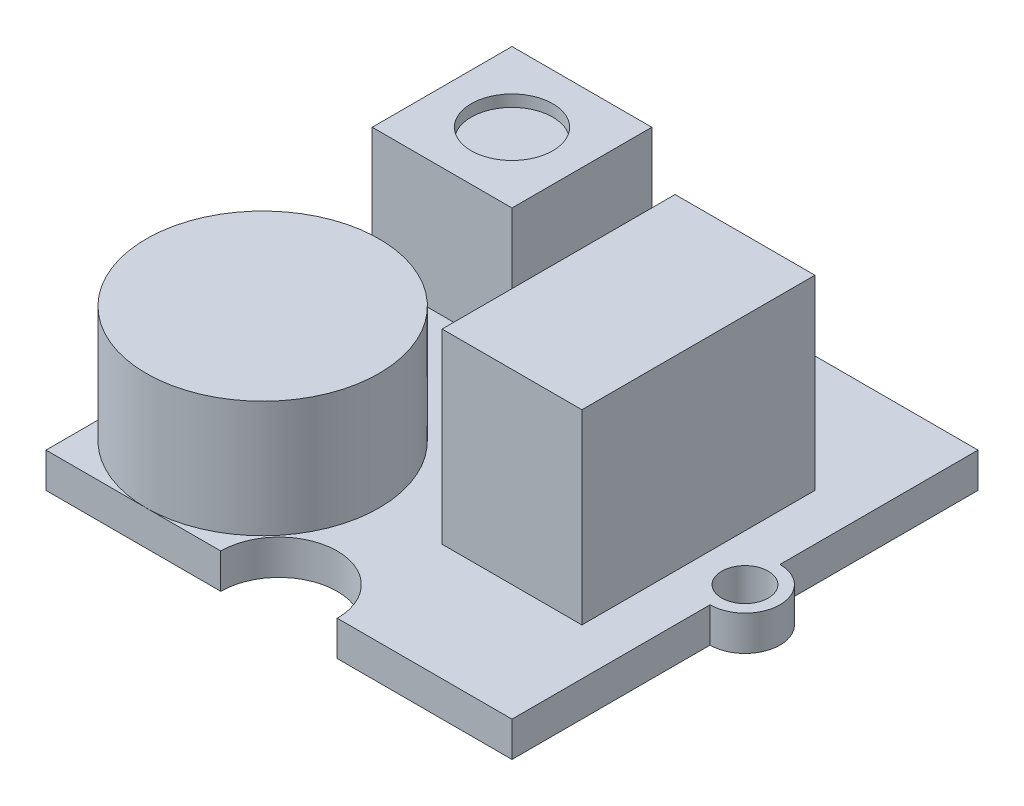
from build123d import *

# Parameters (mm, degrees)
SKETCH1_W           = 20
SKETCH1_H           = 20
BOSS_EXTRUDE1_DEPTH = 1.5
SKETCH2_R           = 1.5
BOSS_EXTRUDE2_DEPTH = 1.5
SKETCH3_R           = 1
SKETCH3_R_2         = 2.5
CUT_EXTRUDE1_DEPTH  = 1.5
SKETCH4_R           = 5
BOSS_EXTRUDE3_DEPTH = 5
SKETCH5_W           = 6
SKETCH5_H           = 6
BOSS_EXTRUDE4_DEPTH = 5.5
SKETCH6_W           = 6
SKETCH6_H           = 10
BOSS_EXTRUDE5_DEPTH = 8
SKETCH7_W           = 3
SKETCH7_H           = 1.820054299
BOSS_EXTRUDE6_DEPTH = 1
SKETCH8_R           = 1.75
CUT_EXTRUDE2_DEPTH  = 0.5


with BuildPart() as part:
    # Sketch1 → Boss-Extrude1 (new body)
    with BuildSketch(Plane(origin=(0, 0, 0), x_dir=(1, 0, 0), z_dir=(0, 1, 0))):
        Rectangle(SKETCH1_W, SKETCH1_H)
    extrude(amount=BOSS_EXTRUDE1_DEPTH)

    # Sketch2 → Boss-Extrude2 (add)
    with BuildSketch(Plane(origin=(0, 1.5, 0), x_dir=(1, 0, 0), z_dir=(0, 1, 0))):
        with Locations((-10, 0)):
            Circle(SKETCH2_R)
        with Locations((10, 0)):
            Circle(SKETCH2_R)
    extrude(amount=-BOSS_EXTRUDE2_DEPTH)

    # Sketch3 → Cut-Extrude1 (cut)
    with BuildSketch(Plane(origin=(0, 1.5, 0), x_dir=(1, 0, 0), z_dir=(0, 1, 0))):
        with Locations((-10, 0)):
            Circle(SKETCH3_R)
        with Locations((10, 0)):
            Circle(SKETCH3_R)
        with Locations((0, 10)):
            Circle(SKETCH3_R_2)
        with Locations((0, -10)):
            Circle(SKETCH3_R_2)
    extrude(amount=-CUT_EXTRUDE1_DEPTH, mode=Mode.SUBTRACT)

    # Sketch4 → Boss-Extrude3 (add)
    with BuildSketch(Plane(origin=(0, 1.5, 0), x_dir=(1, 0, 0), z_dir=(0, 1, 0))):
        with Locations((-5.7, -5)):
            Circle(SKETCH4_R)
    extrude(amount=BOSS_EXTRUDE3_DEPTH)

    # Sketch5 → Boss-Extrude4 (add)
    with BuildSketch(Plane(origin=(0, 1.5, 0), x_dir=(1, 0, 0), z_dir=(0, 1, 0))):
        with Locations((-6.5, 6.5)):
            Rectangle(SKETCH5_W, SKETCH5_H)
    extrude(amount=BOSS_EXTRUDE4_DEPTH)

    # Sketch6 → Boss-Extrude5 (add)
    with BuildSketch(Plane(origin=(0, 1.5, 0), x_dir=(1, 0, 0), z_dir=(0, 1, 0))):
        with Locations((5, 0)):
            Rectangle(SKETCH6_W, SKETCH6_H)
    extrude(amount=BOSS_EXTRUDE5_DEPTH)

    # Sketch7 → Boss-Extrude6 (add)
    with BuildSketch(Plane(origin=(0, 1.5, 0), x_dir=(1, 0, 0), z_dir=(0, 1, 0))):
        with Locations((-0.5, 4.292954161)):
            Rectangle(SKETCH7_W, SKETCH7_H)
    extrude(amount=BOSS_EXTRUDE6_DEPTH)

    # Sketch8 → Cut-Extrude2 (cut)
    with BuildSketch(Plane(origin=(0, 7, 0), x_dir=(1, 0, 0), z_dir=(0, 1, 0))):
        with Locations((-6.5, 6.5)):
            Circle(SKETCH8_R)
    extrude(amount=-CUT_EXTRUDE2_DEPTH, mode=Mode.SUBTRACT)


solid = part.part
